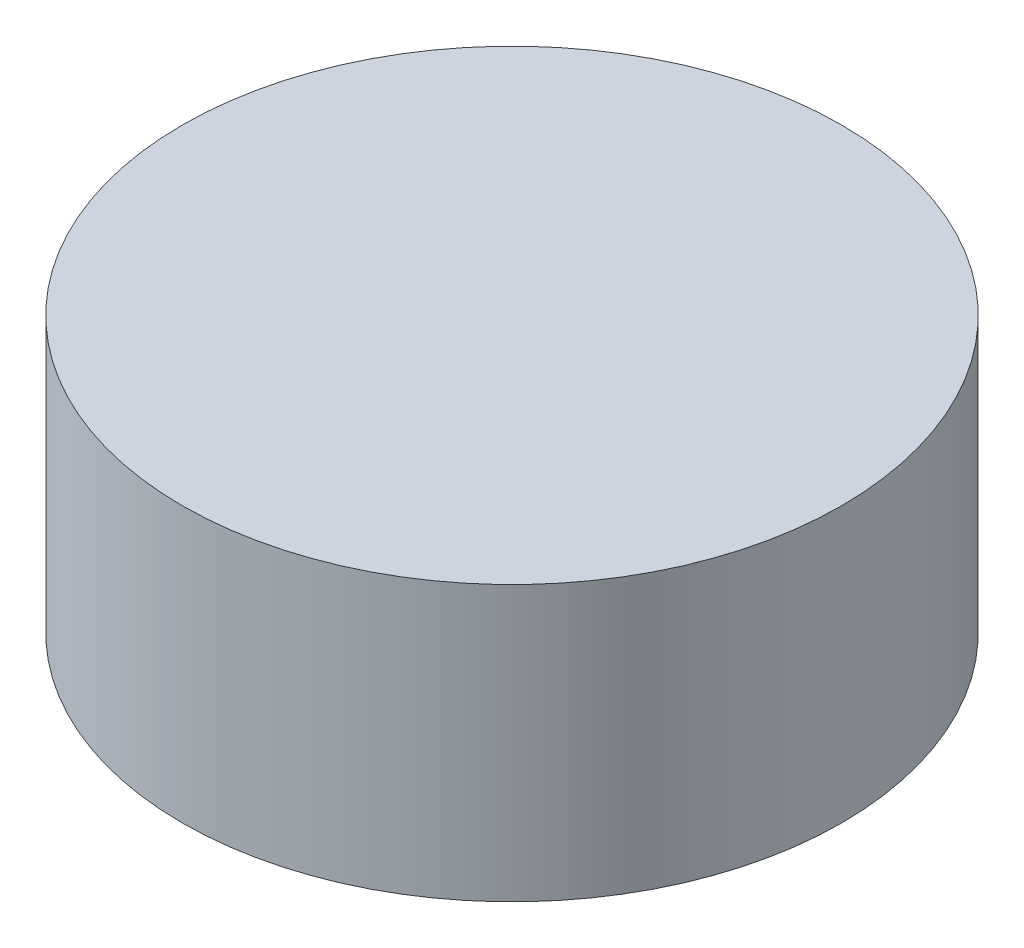
from build123d import *

# Parameters (mm, degrees)
SKETCH1_R           = 3
BOSS_EXTRUDE1_DEPTH = 2.5


with BuildPart() as part:
    # Sketch1 → Boss-Extrude1 (new body)
    with BuildSketch(Plane(origin=(0, 0, 0), x_dir=(1, 0, 0), z_dir=(0, 1, 0))):
        Circle(SKETCH1_R)
    extrude(amount=BOSS_EXTRUDE1_DEPTH)


solid = part.part
